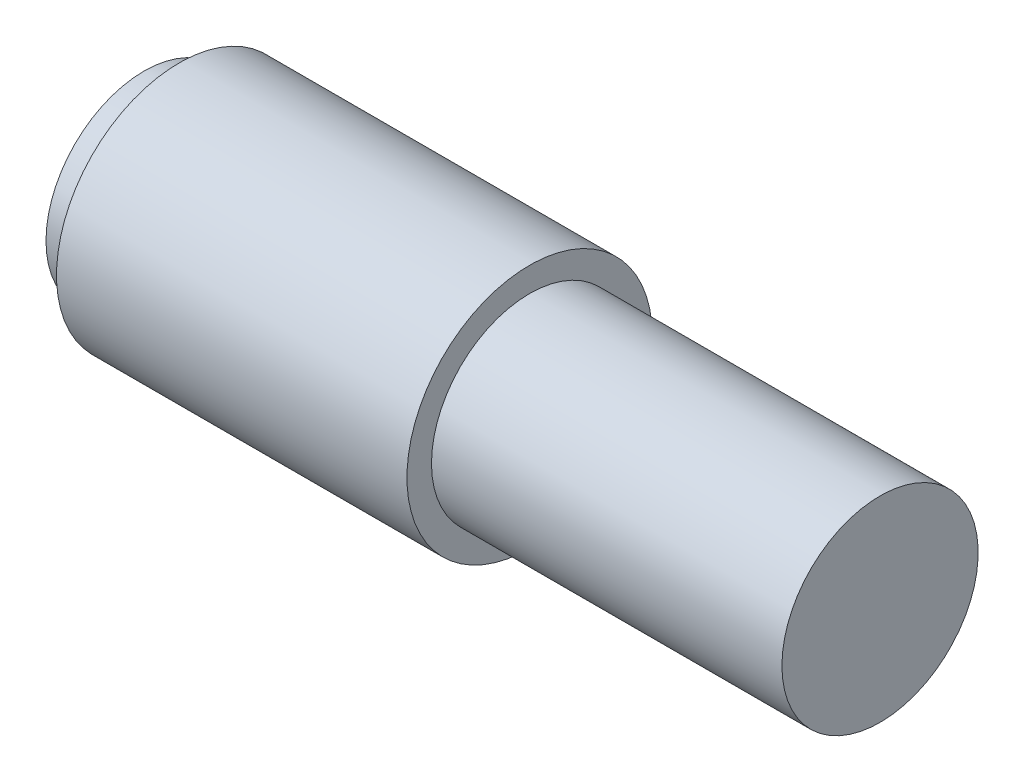
from build123d import *

# Parameters (mm, degrees)
SKETCH1_R           = 1.75
BOSS_EXTRUDE1_DEPTH = 5
SKETCH2_R           = 1.4
BOSS_EXTRUDE2_DEPTH = 10
BOSS_EXTRUDE3_START = 0.5
SKETCH2_2_R         = 1.4
BOSS_EXTRUDE3_DEPTH = 0.5


with BuildPart() as part:
    # Sketch1 → Boss-Extrude1 (new body)
    with BuildSketch(Plane(origin=(0, 0, 0), x_dir=(0, 0, -1), z_dir=(1, 0, 0))):
        Circle(SKETCH1_R)
    extrude(amount=BOSS_EXTRUDE1_DEPTH)

    # Sketch2 → Boss-Extrude2 (add)
    with BuildSketch(Plane.ZY):
        Circle(SKETCH2_R)
    extrude(amount=-BOSS_EXTRUDE2_DEPTH)

    # Sketch2_2 → Boss-Extrude3 (add)
    with BuildSketch(Plane.ZY.offset(BOSS_EXTRUDE3_START)):
        Circle(SKETCH2_2_R)
    extrude(amount=-BOSS_EXTRUDE3_DEPTH)


solid = part.part
